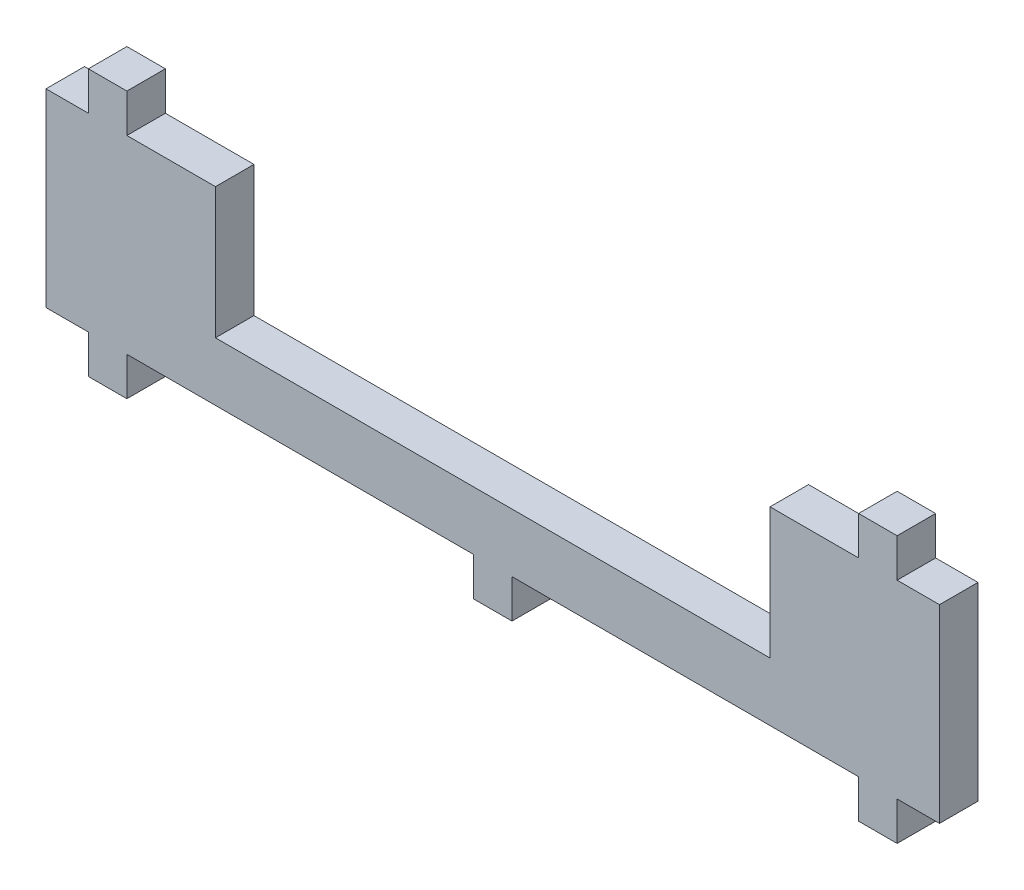
from build123d import *

# Parameters (mm, degrees)
SKETCH1_W           = 116
SKETCH1_H           = 12.3
BOSS_EXTRUDE1_DEPTH = 5
SKETCH2_W           = 5
SKETCH2_H           = 5
BOSS_EXTRUDE2_DEPTH = 5
SKETCH3_W           = 72
SKETCH3_H           = 5
CUT_EXTRUDE1_DEPTH  = 17
SKETCH4_W           = 5
SKETCH4_H           = 5
BOSS_EXTRUDE3_DEPTH = 5


with BuildPart() as part:
    # Sketch1 → Boss-Extrude1 (new body)
    with BuildSketch(Plane.XY):
        Rectangle(SKETCH1_W, SKETCH1_H)
    extrude(amount=BOSS_EXTRUDE1_DEPTH)

    # Sketch2 → Boss-Extrude2 (add)
    with BuildSketch(Plane.XZ.offset(6.15)):
        with Locations((-50, 2.5)):
            Rectangle(SKETCH2_W, SKETCH2_H)
        with Locations((50, 2.5)):
            Rectangle(SKETCH2_W, SKETCH2_H)
    extrude(amount=BOSS_EXTRUDE2_DEPTH)

    # Mirror1: part across plane


with BuildPart() as part_1:
    add(part.part)
    add(part.part.mirror(Plane(origin=(-58, 6.15, 5), x_dir=(0, 0, 1), z_dir=(0, -1, 0))))

    # Sketch3 → Cut-Extrude1 (cut)
    with BuildSketch(Plane(origin=(0, 18.45, 0), x_dir=(1, 0, 0), z_dir=(0, 1, 0))):
        with Locations((0, -2.5)):
            Rectangle(SKETCH3_W, SKETCH3_H)
    extrude(amount=-CUT_EXTRUDE1_DEPTH, mode=Mode.SUBTRACT)

    # Sketch4 → Boss-Extrude3 (add)
    with BuildSketch(Plane.XZ.offset(6.15)):
        with Locations((0, 2.5)):
            Rectangle(SKETCH4_W, SKETCH4_H)
    extrude(amount=BOSS_EXTRUDE3_DEPTH)


solid = part_1.part
